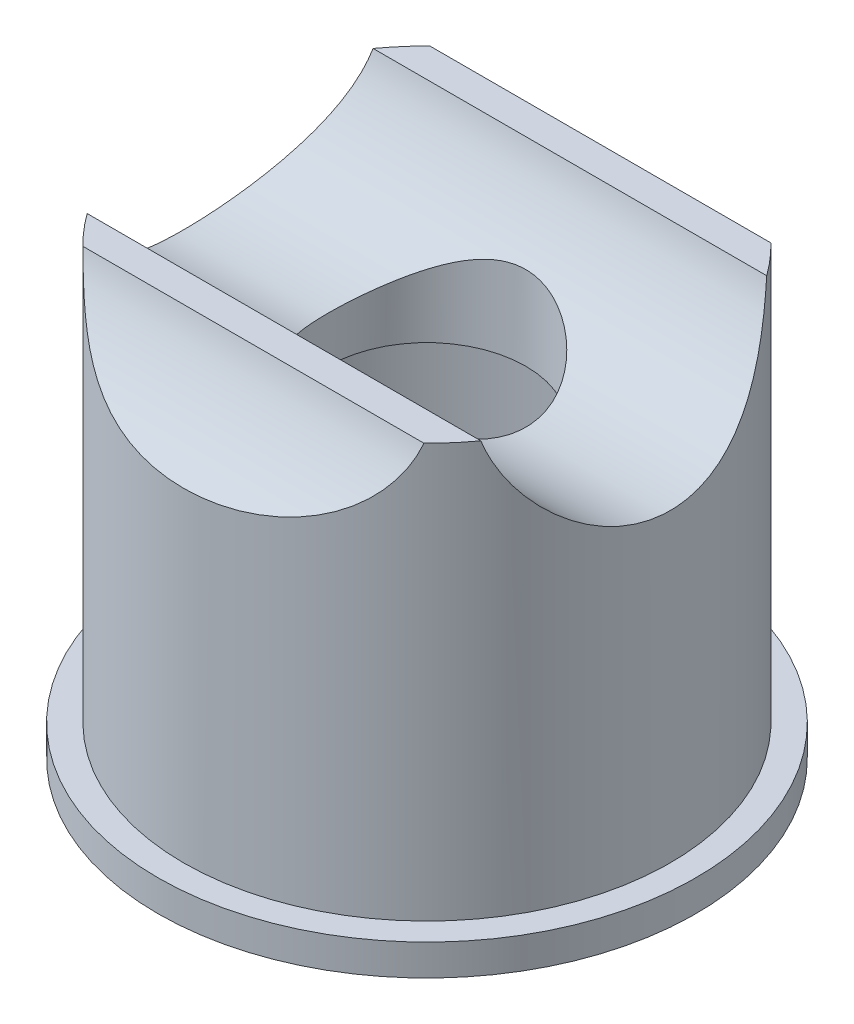
from build123d import *

# Parameters (mm, degrees)
SKETCH1_R               = 8.636
BOSS_EXTRUDE1_DEPTH     = 14.2875
SKETCH5_R               = 4.7625
CUT_EXTRUDE4_DEPTH      = 9.636
CUT_EXTRUDE4_DEPTH_BACK = 9.636
SKETCH2_OUTSIDE_W       = 24.932
SKETCH2_OUTSIDE_H       = 24.932
SKETCH2_OUTSIDE_R       = 7.8105
CUT_EXTRUDE1_DEPTH      = 13.2875
SKETCH4_R               = 3.175
CUT_EXTRUDE3_DEPTH      = 15.2875
SKETCH3_R               = 6.7818
CUT_EXTRUDE2_DEPTH      = 9.31875
FILLET1_R               = 1


with BuildPart() as part:
    # Sketch1 → Boss-Extrude1 (new body)
    with BuildSketch(Plane(origin=(0, 0, 0), x_dir=(1, 0, 0), z_dir=(0, 1, 0))):
        Circle(SKETCH1_R)
    extrude(amount=BOSS_EXTRUDE1_DEPTH)

    # Sketch5 → Cut-Extrude4 (cut, two sides)
    with BuildSketch(Plane(origin=(0, 0, 0), x_dir=(0, 0, -1), z_dir=(1, 0, 0))) as cut_extrude4_sk:
        with Locations((0, 15.5575)):
            Circle(SKETCH5_R)
        with Locations((-10.16, 15.5575)):
            Circle(SKETCH5_R)
        with Locations((10.16, 15.5575)):
            Circle(SKETCH5_R)
    extrude(amount=CUT_EXTRUDE4_DEPTH, mode=Mode.SUBTRACT)
    extrude(cut_extrude4_sk.sketch, amount=-CUT_EXTRUDE4_DEPTH_BACK, mode=Mode.SUBTRACT)

    # Sketch2 outside → Cut-Extrude1 (cut)
    with BuildSketch(Plane(origin=(0, 14.2875, 0), x_dir=(1, 0, 0), z_dir=(0, 1, 0))):
        Rectangle(SKETCH2_OUTSIDE_W, SKETCH2_OUTSIDE_H)
        Circle(SKETCH2_OUTSIDE_R, mode=Mode.SUBTRACT)
    extrude(amount=-CUT_EXTRUDE1_DEPTH, mode=Mode.SUBTRACT)

    # Sketch4 → Cut-Extrude3 (cut, through all)
    with BuildSketch(Plane(origin=(0, 14.2875, 0), x_dir=(1, 0, 0), z_dir=(0, 1, 0))):
        Circle(SKETCH4_R)
    extrude(amount=-CUT_EXTRUDE3_DEPTH, mode=Mode.SUBTRACT)

    # Sketch3 → Cut-Extrude2 (cut)
    with BuildSketch(Plane.XZ):
        Circle(SKETCH3_R)
    extrude(amount=-CUT_EXTRUDE2_DEPTH, mode=Mode.SUBTRACT)

    # Fillet1
    fillet1_edges = [part.edges().sort_by_distance(p)[0] for p in [
        (-6.7818, 0, 0),
    ]]
    fillet(fillet1_edges, radius=FILLET1_R)


solid = part.part
